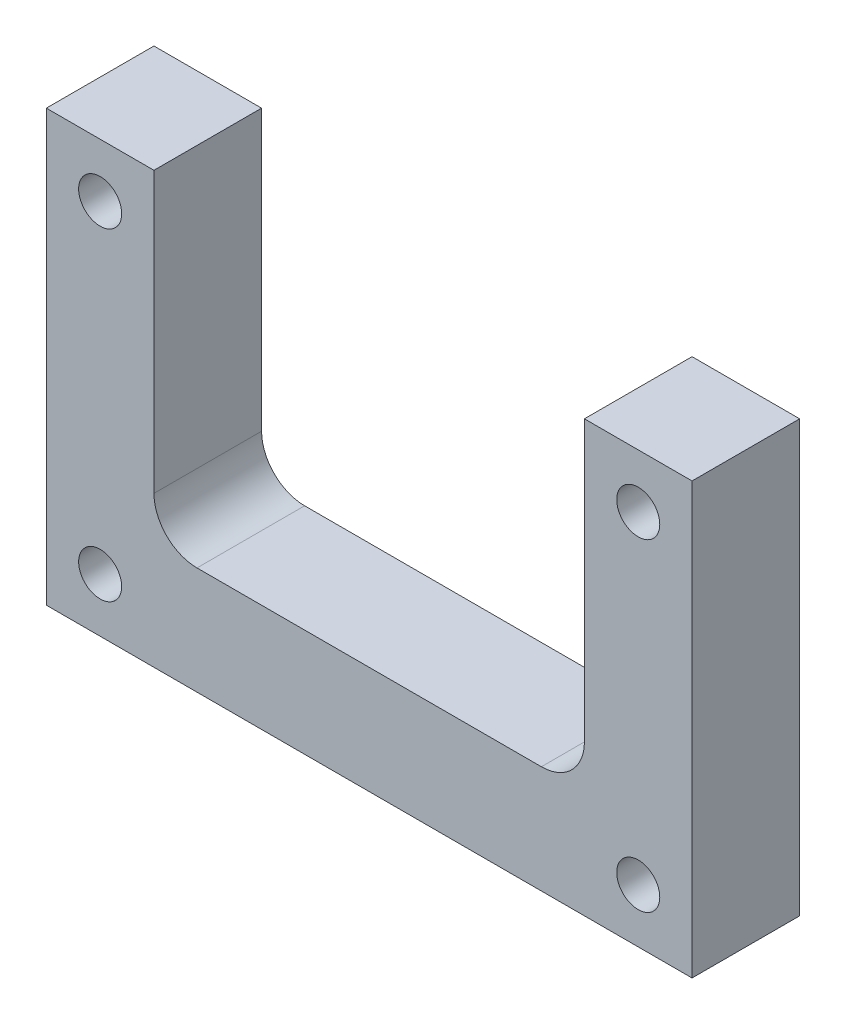
from build123d import *

# Parameters (mm, degrees)
BOSS_EXTRUDE1_DEPTH     = 12.7
SKETCH4_R               = 2.54
CUT_EXTRUDE3_DEPTH      = 13.7
CUT_EXTRUDE3_DEPTH_BACK = 1
FILLET1_R               = 5.08


with BuildPart() as part:
    # Sketch2 → Boss-Extrude1 (new body)
    with BuildSketch(Plane.XY):
        Polygon((-25.4, 25.4), (-25.4, -12.7), (25.4, -12.7), (25.4, 25.4), (38.1, 25.4), (38.1, -25.4), (-38.1, -25.4), (-38.1, 25.4), align=None)
    extrude(amount=BOSS_EXTRUDE1_DEPTH)

    # Sketch4 → Cut-Extrude3 (cut, two sides)
    with BuildSketch(Plane.XY) as cut_extrude3_sk:
        with Locations((-31.75, 19.05)):
            Circle(SKETCH4_R)
        with Locations((31.75, 19.05)):
            Circle(SKETCH4_R)
        with Locations((31.75, -19.05)):
            Circle(SKETCH4_R)
        with Locations((-31.75, -19.05)):
            Circle(SKETCH4_R)
    extrude(amount=CUT_EXTRUDE3_DEPTH, mode=Mode.SUBTRACT)
    extrude(cut_extrude3_sk.sketch, amount=-CUT_EXTRUDE3_DEPTH_BACK, mode=Mode.SUBTRACT)

    # Fillet1
    fillet1_edges = [part.edges().sort_by_distance(p)[0] for p in [
        (-25.4, -12.7, 6.35),
        (25.4, -12.7, 6.35),
    ]]
    fillet(fillet1_edges, radius=FILLET1_R)


solid = part.part
